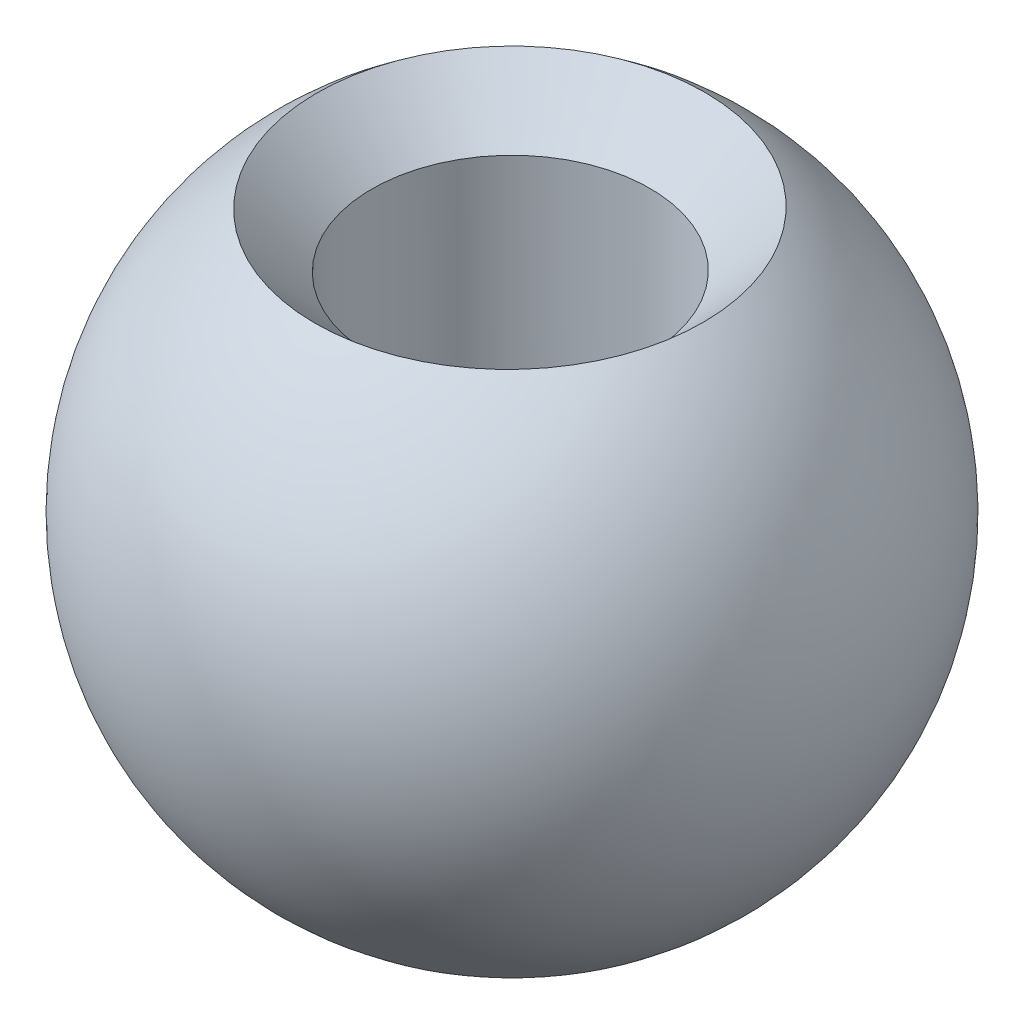
from build123d import *

# Parameters (mm, degrees)
HOLE_WIZARD_M32_D           = 3.4
HOLE_WIZARD_M32_CSINK_D     = 6.3
HOLE_WIZARD_M32_CSINK_ANGLE = 90


with BuildPart() as part:
    # Эскиз1 → Повернуть1 (revolve)
    with BuildSketch(Plane(origin=(0, 0, 0), x_dir=(1, 0, 0), z_dir=(0, 1, 0))):
        with BuildLine():
            Line((4, 0), (-4, 0))
            ThreePointArc((-4, 0), (0, 4), (4, 0))
        make_face()
    revolve(axis=Axis((4, 0, 0), (-1, 0, 0)))

    # Зенковка для  винта с плоской головкой M32 (through all)
    with Locations(Plane(origin=(0.01155175, 3.999743344, 0.043814802), x_dir=(0, -0.010953746, 0.999940006), z_dir=(0.002887938, 0.999935836, 0.010953701))):
        with Locations((0, 0)):
            CounterSinkHole(HOLE_WIZARD_M32_D / 2, HOLE_WIZARD_M32_CSINK_D / 2, counter_sink_angle=HOLE_WIZARD_M32_CSINK_ANGLE)


solid = part.part
